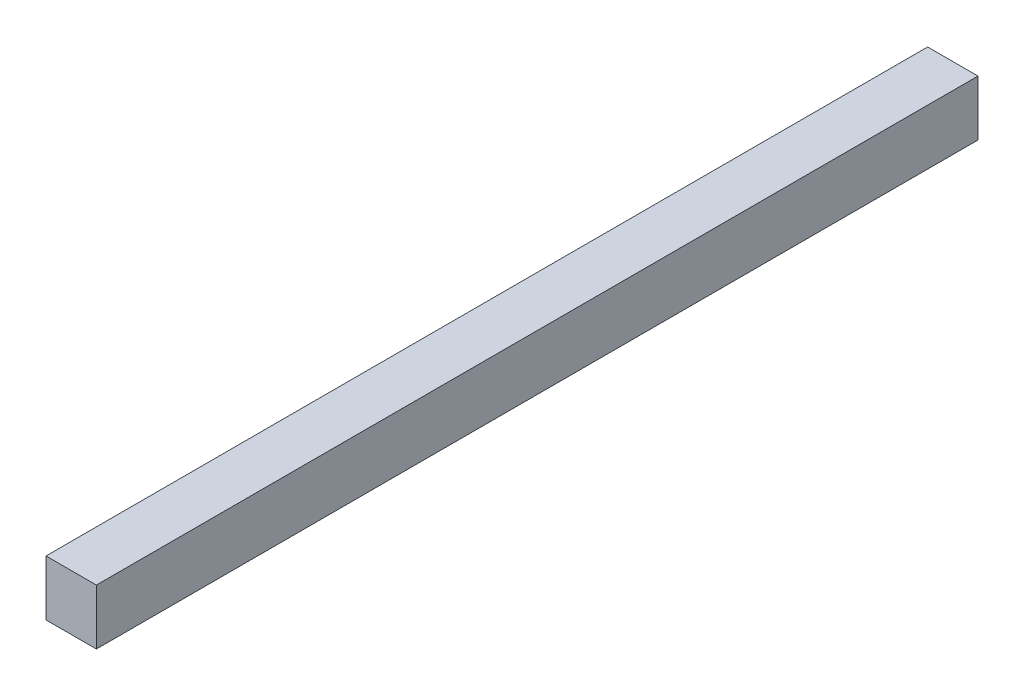
from build123d import *

# Parameters (mm, degrees)
SKETCH_1_W      = 2
SKETCH_1_H      = 2.2
EXTRUDE_1_DEPTH = 35


with BuildPart() as part:
    # 草图1 → 凸台-拉伸1 (new body)
    with BuildSketch(Plane.XY):
        with Locations((1, -1.1)):
            Rectangle(SKETCH_1_W, SKETCH_1_H)
    extrude(amount=EXTRUDE_1_DEPTH)


solid = part.part
